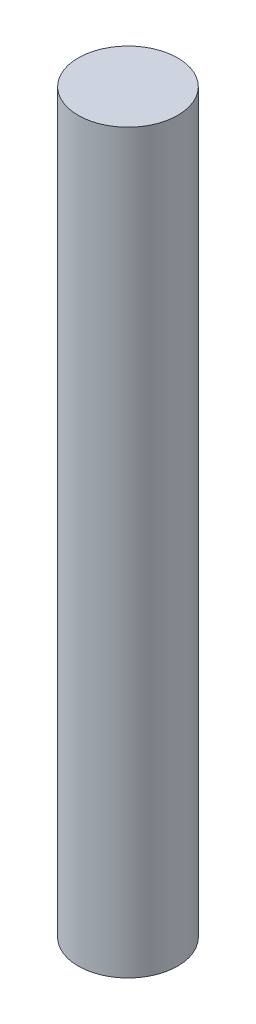
from build123d import *

# Parameters (mm, degrees)
SCHIZZO1_R                   = 8
ESTRUSIONE_ESTRUSIONE1_DEPTH = 118.46


with BuildPart() as part:
    # Schizzo1 → Estrusione-Estrusione1 (new body)
    with BuildSketch(Plane(origin=(0, 0, 0), x_dir=(1, 0, 0), z_dir=(0, 1, 0))):
        Circle(SCHIZZO1_R)
    extrude(amount=ESTRUSIONE_ESTRUSIONE1_DEPTH)


solid = part.part
